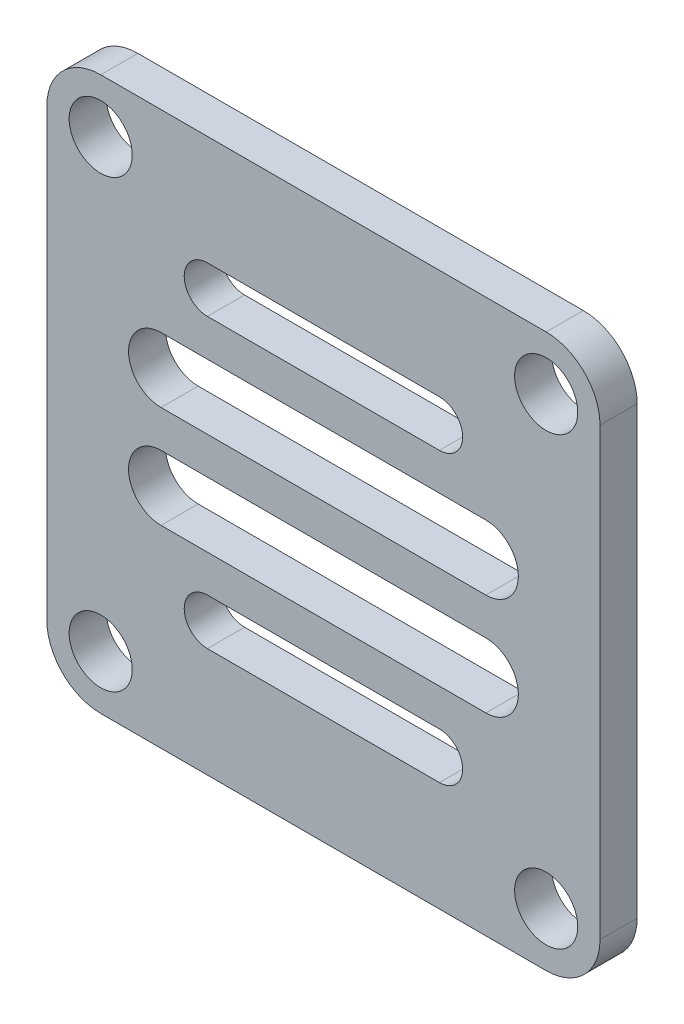
from build123d import *

# Parameters (mm, degrees)
SKETCH1_R               = 1.7
BOSS_EXTRUDE1_DEPTH     = 2
CUT_EXTRUDE1_DEPTH      = 1
CUT_EXTRUDE1_DEPTH_BACK = 3


with BuildPart() as part:
    # Sketch1 → Boss-Extrude1 (new body)
    with BuildSketch(Plane.XY):
        with BuildLine():
            ThreePointArc((-29.5, 16.4), (-31.550609665, 15.550609665), (-32.4, 13.5))
            Line((-32.4, 13.5), (-32.4, -10.5))
            ThreePointArc((-32.4, -10.5), (-31.550609665, -12.550609665), (-29.5, -13.4))
            Line((-29.5, -13.4), (-5.5, -13.4))
            ThreePointArc((-5.5, -13.4), (-3.449390335, -12.550609665), (-2.6, -10.5))
            Line((-2.6, -10.5), (-2.6, 13.5))
            ThreePointArc((-2.6, 13.5), (-3.449390335, 15.550609665), (-5.5, 16.4))
            Line((-5.5, 16.4), (-29.5, 16.4))
        make_face()
        with Locations((-29.5, -10.5)):
            Circle(SKETCH1_R, mode=Mode.SUBTRACT)
        with Locations((-5.5, -10.5)):
            Circle(SKETCH1_R, mode=Mode.SUBTRACT)
        with Locations((-29.5, 13.5)):
            Circle(SKETCH1_R, mode=Mode.SUBTRACT)
        with Locations((-5.5, 13.5)):
            Circle(SKETCH1_R, mode=Mode.SUBTRACT)
    extrude(amount=-BOSS_EXTRUDE1_DEPTH)

    # Sketch3 → Cut-Extrude1 (cut, two sides)
    with BuildSketch(Plane.XY) as cut_extrude1_sk:
        with BuildLine():
            Line((-23.75, 10.5), (-11.25, 10.5))
            ThreePointArc((-11.25, 10.5), (-10, 9.25), (-11.25, 8))
            Line((-11.25, 8), (-23.75, 8))
            ThreePointArc((-23.75, 8), (-25, 9.25), (-23.75, 10.5))
        make_face()
        with BuildLine():
            Line((-26.25, 6), (-8.75, 6))
            ThreePointArc((-8.75, 6), (-7, 4.25), (-8.75, 2.5))
            Line((-8.75, 2.5), (-26.25, 2.5))
            ThreePointArc((-26.25, 2.5), (-28, 4.25), (-26.25, 6))
        make_face()
        with BuildLine():
            Line((-26.25, -3), (-8.75, -3))
            ThreePointArc((-8.75, -3), (-7, -1.25), (-8.75, 0.5))
            Line((-8.75, 0.5), (-26.25, 0.5))
            ThreePointArc((-26.25, 0.5), (-28, -1.25), (-26.25, -3))
        make_face()
        with BuildLine():
            Line((-23.75, -7.5), (-11.25, -7.5))
            ThreePointArc((-11.25, -7.5), (-10, -6.25), (-11.25, -5))
            Line((-11.25, -5), (-23.75, -5))
            ThreePointArc((-23.75, -5), (-25, -6.25), (-23.75, -7.5))
        make_face()
    extrude(amount=CUT_EXTRUDE1_DEPTH, mode=Mode.SUBTRACT)
    extrude(cut_extrude1_sk.sketch, amount=-CUT_EXTRUDE1_DEPTH_BACK, mode=Mode.SUBTRACT)


solid = part.part
